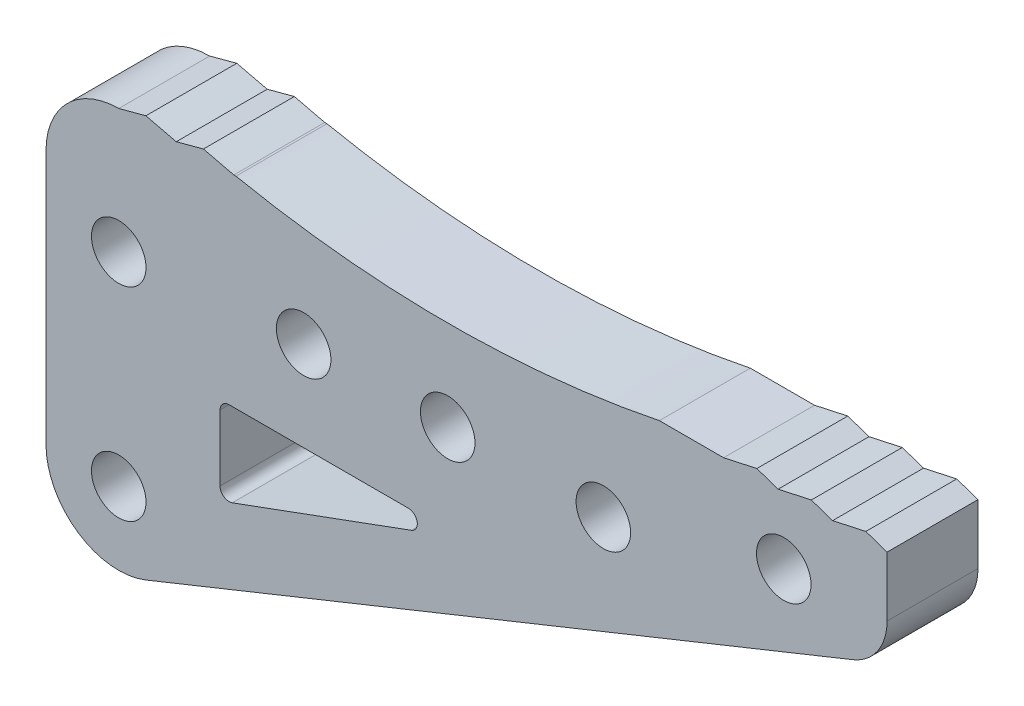
from build123d import *

# Parameters (mm, degrees)
SKETCH1_R           = 1.5
BOSS_EXTRUDE1_DEPTH = 5


with BuildPart() as part:
    # Sketch1 → Boss-Extrude1 (new body)
    with BuildSketch(Plane.XY):
        with BuildLine():
            Line((90.09046413, 17.581004237), (128.971852367, 33.226333782))
            ThreePointArc((128.971852367, 33.226333782), (130.33788662, 34.330135362), (130.851957871, 36.009468044))
            Line((130.851957871, 36.009468044), (130.851957871, 39.291849919))
            Line((130.851957871, 39.291849919), (129.683368149, 39.691849919))
            Line((129.683368149, 39.691849919), (127.855440432, 39.291849919))
            Line((127.855440432, 39.291849919), (126.68685071, 39.691849919))
            Line((126.68685071, 39.691849919), (124.858922992, 39.291849919))
            Line((124.858922992, 39.291849919), (123.69033327, 39.691849919))
            Line((123.69033327, 39.691849919), (121.862405553, 39.291849919))
            Line((121.862405553, 39.291849919), (118.330499072, 39.291849919))
            ThreePointArc((118.330499072, 39.291849919), (106.6886691, 38.118374493), (95.046839129, 39.291849919))
            Line((95.046839129, 39.291849919), (94.926233776, 39.291849919))
            Line((94.926233776, 39.291849919), (93.254945284, 39.691849919))
            Line((93.254945284, 39.691849919), (91.761752622, 39.291849919))
            Line((91.761752622, 39.291849919), (90.09046413, 39.691849919))
            Line((90.09046413, 39.691849919), (88.597271468, 39.291849919))
            ThreePointArc((88.597271468, 39.291849919), (85.768844343, 38.120277044), (84.597271468, 35.291849919))
            Line((84.597271468, 35.291849919), (84.597271468, 21.291849919))
            ThreePointArc((84.597271468, 21.291849919), (86.358161226, 17.977278254), (90.09046413, 17.581004237))
        make_face()
        with Locations((88.597271468, 32.460805113)):
            Circle(SKETCH1_R, mode=Mode.SUBTRACT)
        with BuildLine():
            Line((94.167132873, 24.101877808), (94.167132873, 27.719143002))
            ThreePointArc((94.167132873, 27.719143002), (94.313579482, 28.072696393), (94.667132873, 28.219143002))
            Line((94.667132873, 28.219143002), (104.518408295, 28.219143002))
            ThreePointArc((104.518408295, 28.219143002), (105.010688474, 27.806665718), (104.690751088, 27.249783905))
            Line((104.690751088, 27.249783905), (94.839475666, 23.632518711))
            ThreePointArc((94.839475666, 23.632518711), (94.380926126, 23.691895249), (94.167132873, 24.101877808))
        make_face(mode=Mode.SUBTRACT)
        with Locations((115.248465962, 33.15691525)):
            Circle(SKETCH1_R, mode=Mode.SUBTRACT)
        with Locations((125.169093906, 35.649647236)):
            Circle(SKETCH1_R, mode=Mode.SUBTRACT)
        with Locations((98.766505389, 33.15691525)):
            Circle(SKETCH1_R, mode=Mode.SUBTRACT)
        with Locations((106.6886691, 33.15691525)):
            Circle(SKETCH1_R, mode=Mode.SUBTRACT)
        with Locations((88.597271468, 21.291849919)):
            Circle(SKETCH1_R, mode=Mode.SUBTRACT)
    extrude(amount=BOSS_EXTRUDE1_DEPTH)


solid = part.part
